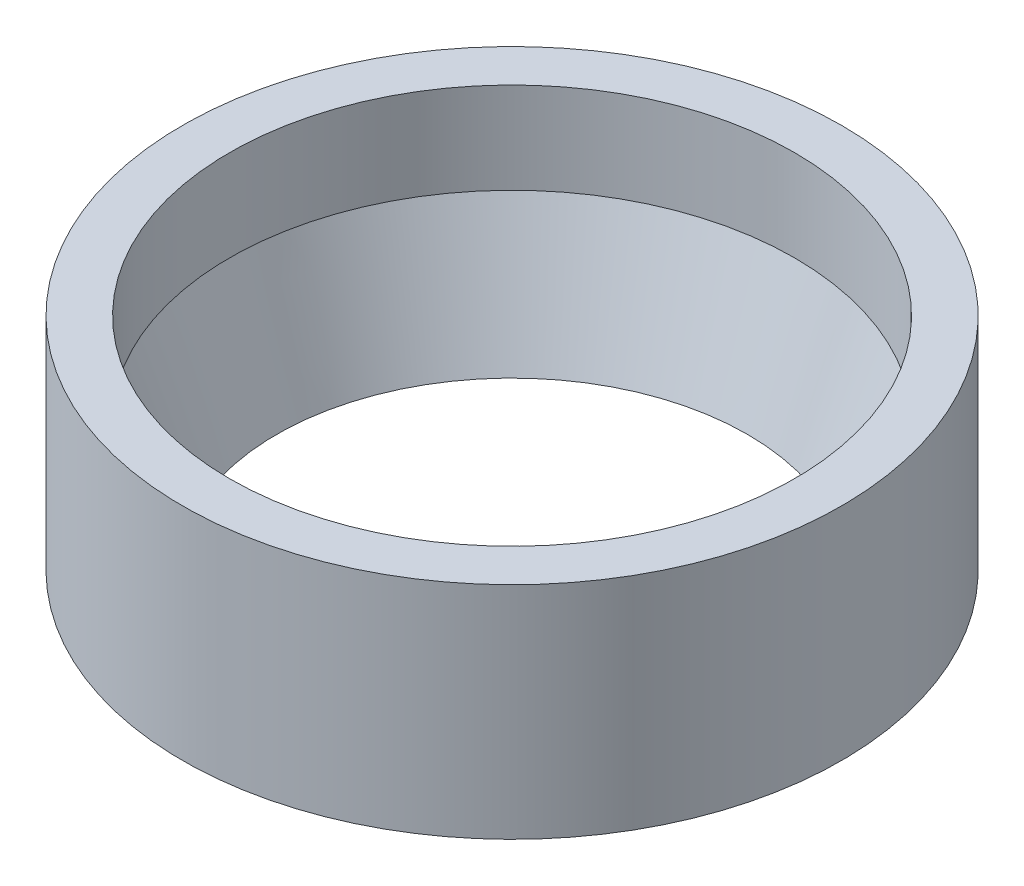
from build123d import *


with BuildPart() as part:
    # Sketch1 → Revolve1 (revolve)
    with BuildSketch(Plane.XY):
        Polygon((-38.1, 0), (-38.1, -12.296918386), (-31.75, -29.7434), (-44.45, -29.7434), (-44.45, 0), align=None)
    revolve(axis=Axis((0, 0, 0), (0, 1, 0)))


solid = part.part
